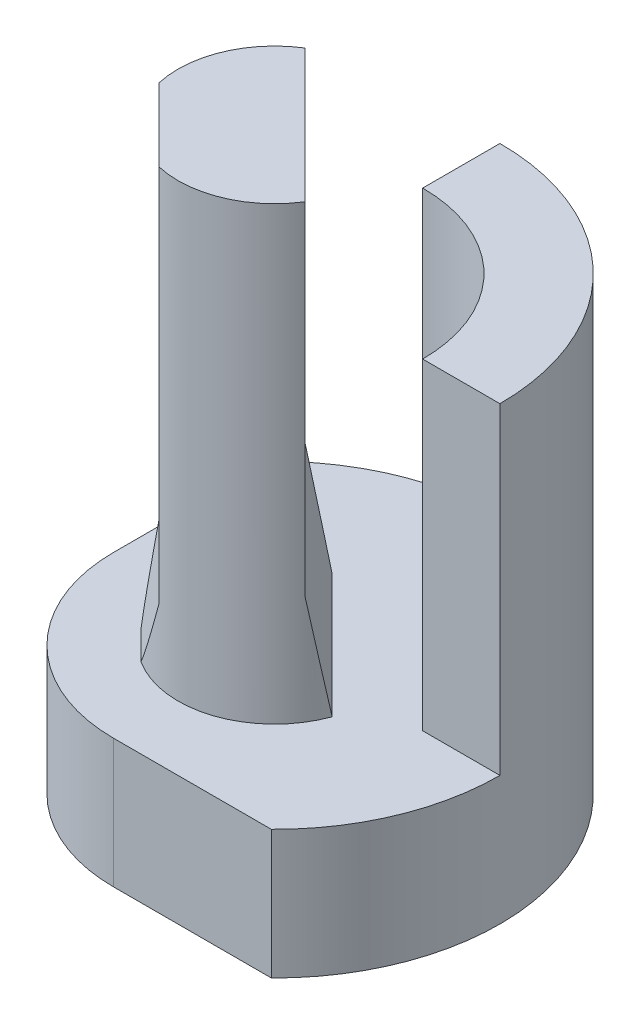
from build123d import *

# Parameters (mm, degrees)
SKETCH1_R           = 3.5
BOSS_EXTRUDE1_DEPTH = 2
SKETCH2_R           = 1.5
BOSS_EXTRUDE2_DEPTH = 7
SKETCH5_OUTSIDE_W   = 11.676
SKETCH5_OUTSIDE_H   = 11.676
CUT_EXTRUDE1_DEPTH  = 7
BOSS_EXTRUDE4_DEPTH = 5
CHAMFER3_SIZE       = 0.3
CHAMFER3_SIZE2      = 1.701384546
CHAMFER4_SIZE       = 0.2
CHAMFER4_SIZE2      = 1.134256364
CUT_EXTRUDE2_DEPTH  = 3


with BuildPart() as part:
    # Sketch1 → Boss-Extrude1 (new body)
    with BuildSketch(Plane(origin=(0, 0, 0), x_dir=(1, 0, 0), z_dir=(0, 1, 0))):
        Circle(SKETCH1_R)
    extrude(amount=BOSS_EXTRUDE1_DEPTH)

    # Sketch2 → Boss-Extrude2 (add)
    with BuildSketch(Plane(origin=(0, 2, 0), x_dir=(1, 0, 0), z_dir=(0, 1, 0))):
        Circle(SKETCH2_R)
    extrude(amount=BOSS_EXTRUDE2_DEPTH)

    # Sketch5 outside → Cut-Extrude1 (cut)
    with BuildSketch(Plane(origin=(0, 2, 0), x_dir=(1, 0, 0), z_dir=(0, 1, 0))):
        Rectangle(SKETCH5_OUTSIDE_W, SKETCH5_OUTSIDE_H)
        with BuildLine():
            Line((-2.228687609, 2.698694414), (2.698694414, -2.228687609))
            ThreePointArc((2.698694414, -2.228687609), (2.111573719, -2.791282219), (1.41047572, -3.203210615))
            Line((1.41047572, -3.203210615), (-3.203210615, 1.41047572))
            ThreePointArc((-3.203210615, 1.41047572), (-2.791282219, 2.111573719), (-2.228687609, 2.698694414))
        make_face(mode=Mode.SUBTRACT)
    extrude(amount=CUT_EXTRUDE1_DEPTH, mode=Mode.SUBTRACT)

    # Sketch4 → Boss-Extrude4 (add)
    with BuildSketch(Plane(origin=(0, 2, 0), x_dir=(1, 0, 0), z_dir=(0, 1, 0))):
        with BuildLine():
            Line((0, 2.3), (0, 3.5))
            ThreePointArc((0, 3.5), (2.474873734, 2.474873734), (3.5, 0))
            Line((3.5, 0), (2.3, 0))
            ThreePointArc((2.3, 0), (1.626345597, 1.626345597), (0, 2.3))
        make_face()
    extrude(amount=BOSS_EXTRUDE4_DEPTH)

    # Chamfer3
    chamfer3_edges = [part.edges().sort_by_distance(p)[0] for p in [
        (0.235003403, 2, -0.235003403),
    ]]
    chamfer3_side = [part.faces().sort_by_distance(p)[0] for p in [
        (-2.404873734, 2, 2.404873734),
    ]]
    chamfer(chamfer3_edges, length=CHAMFER3_SIZE, length2=CHAMFER3_SIZE2, reference=chamfer3_side[0])

    # Chamfer4
    chamfer4_edges = [part.edges().sort_by_distance(p)[0] for p in [
        (-0.896367447, 2, 0.896367447),
    ]]
    chamfer4_side = [part.faces().sort_by_distance(p)[0] for p in [
        (-0.704284953, 2, -1.435537374),
    ]]
    chamfer(chamfer4_edges, length=CHAMFER4_SIZE, length2=CHAMFER4_SIZE2, reference=chamfer4_side[0])

    # Sketch6 → Cut-Extrude2 (cut, through all)
    with BuildSketch(Plane(origin=(0, 2, 0), x_dir=(1, 0, 0), z_dir=(0, 1, 0))):
        with BuildLine():
            Line((-2.5, 0), (-2.5, 2.449489743))
            ThreePointArc((-2.5, 2.449489743), (-2.474873734, -2.474873734), (2.449489743, -2.5))
            Line((2.449489743, -2.5), (0, -2.5))
            ThreePointArc((0, -2.5), (-1.767766953, -1.767766953), (-2.5, 0))
        make_face()
    extrude(amount=-CUT_EXTRUDE2_DEPTH, mode=Mode.SUBTRACT)


solid = part.part
